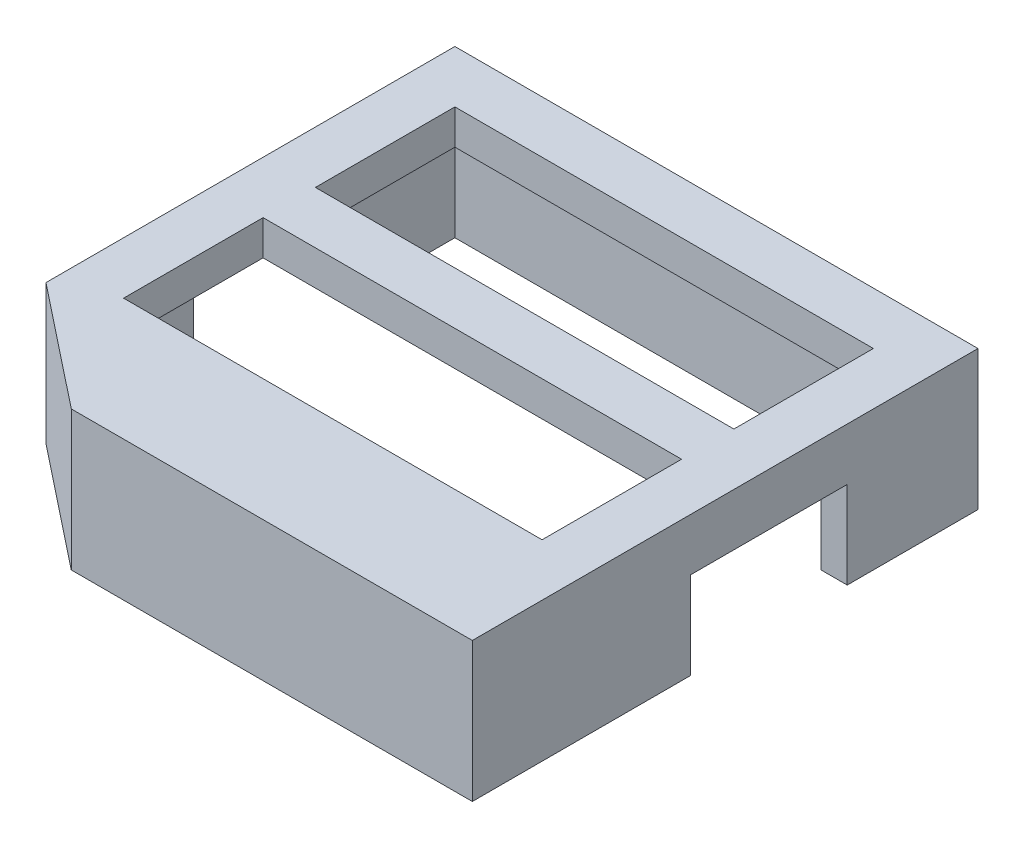
from build123d import *

# Parameters (mm, degrees)
SKETCH1_W           = 30
SKETCH1_H           = 29
BOSS_EXTRUDE1_DEPTH = 8
SKETCH2_W           = 24
SKETCH2_H           = 8
CUT_EXTRUDE1_DEPTH  = 8
CUT_EXTRUDE2_DEPTH  = 8
CUT_EXTRUDE3_DEPTH  = 6
BELT_CUTOUT_W       = 9
BELT_CUTOUT_H       = 5
CUT_EXTRUDE4_DEPTH  = 30


with BuildPart() as part:
    # Sketch1 → Boss-Extrude1 (new body)
    with BuildSketch(Plane(origin=(0, 0, 0), x_dir=(1, 0, 0), z_dir=(0, 1, 0))):
        with Locations((-14.236607143, -13.569196429)):
            Rectangle(SKETCH1_W, SKETCH1_H)
    extrude(amount=BOSS_EXTRUDE1_DEPTH)

    # Sketch2 → Cut-Extrude1 (cut)
    with BuildSketch(Plane(origin=(0, 8, 0), x_dir=(1, 0, 0), z_dir=(0, 1, 0))):
        with Locations((-14.236607143, -6.069196429)):
            Rectangle(SKETCH2_W, SKETCH2_H)
        with Locations((-14.236607143, -17.069196429)):
            Rectangle(SKETCH2_W, SKETCH2_H)
    extrude(amount=-CUT_EXTRUDE1_DEPTH, mode=Mode.SUBTRACT)

    # Sketch3 → Cut-Extrude2 (cut)
    with BuildSketch(Plane(origin=(0, 8, 0), x_dir=(1, 0, 0), z_dir=(0, 1, 0))):
        Polygon((-29.236607143, -22.519140749), (-22.236607143, -28.069196429), (-29.236607143, -28.069196429), align=None)
    extrude(amount=-CUT_EXTRUDE2_DEPTH, mode=Mode.SUBTRACT)

    # cutout → Cut-Extrude3 (cut)
    with BuildSketch(Plane.XZ):
        Polygon((-0.736607143, 0.569196429), (-27.736607143, 0.569196429), (-27.736607143, 21.794168589), (-21.714109927, 26.569196429), (-0.736607143, 26.569196429), align=None)
    extrude(amount=-CUT_EXTRUDE3_DEPTH, mode=Mode.SUBTRACT)

    # belt_cutout → Cut-Extrude4 (cut)
    with BuildSketch(Plane.ZY.offset(29.236607143)):
        with Locations((11.069196429, 2.5)):
            Rectangle(BELT_CUTOUT_W, BELT_CUTOUT_H)
    extrude(amount=-CUT_EXTRUDE4_DEPTH, mode=Mode.SUBTRACT)


solid = part.part
